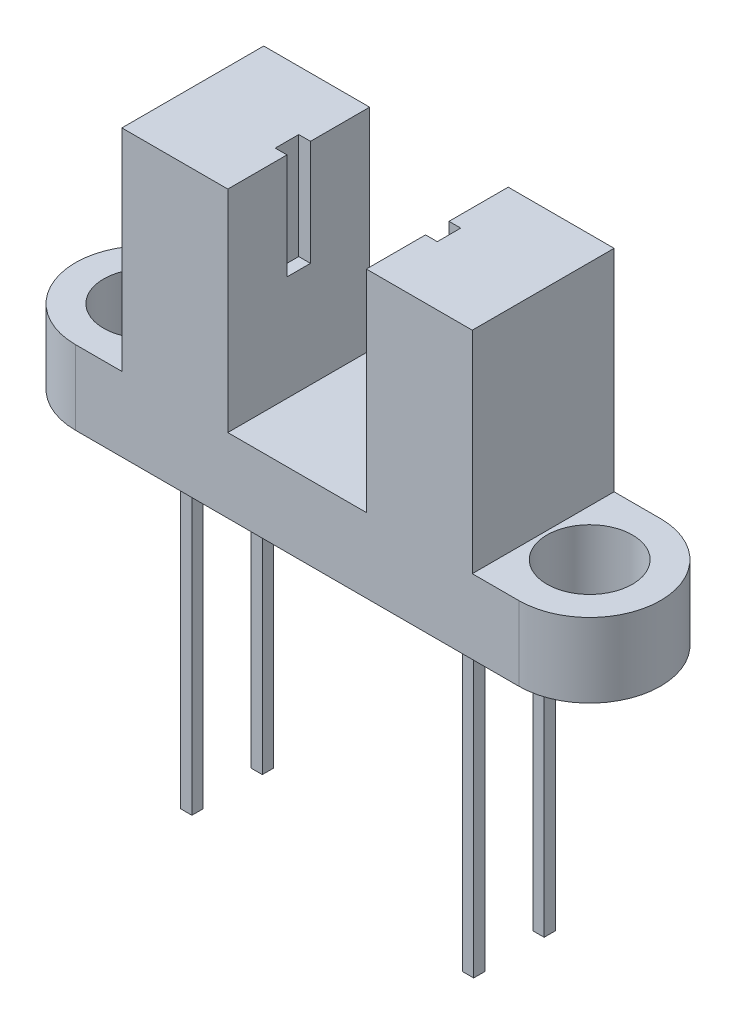
from build123d import *

# Parameters (mm, degrees)
CROQUIS1_R                = 1.82
SALIENTE_EXTRUIR1_DEPTH   = 3.16
CROQUIS2_W                = 4.51
CROQUIS2_H                = 6.04
SALIENTE_EXTRUIR2_DEPTH   = 8.98
CROQUIS3_W                = 0.48
CROQUIS3_H                = 0.48
SALIENTE_EXTRUIR3_DEPTH   = 13
SALIENTE_EXTRUIR3_2_DEPTH = 13
SALIENTE_EXTRUIR3_3_DEPTH = 13
SALIENTE_EXTRUIR3_4_DEPTH = 13
CROQUIS4_W                = 6.9
CROQUIS4_H                = 1
CORTAR_EXTRUIR1_DEPTH     = 4.5


with BuildPart() as part:
    # Croquis1 → Saliente-Extruir1 (new body)
    with BuildSketch(Plane(origin=(0, 0, 0), x_dir=(1, 0, 0), z_dir=(0, 1, 0))):
        with BuildLine():
            Line((-9.44, 3.02), (9.44, 3.02))
            ThreePointArc((9.44, 3.02), (12.46, 0), (9.44, -3.02))
            Line((9.44, -3.02), (-9.44, -3.02))
            ThreePointArc((-9.44, -3.02), (-12.46, 0), (-9.44, 3.02))
        make_face()
        with Locations((-9.44, 0)):
            Circle(CROQUIS1_R, mode=Mode.SUBTRACT)
        with Locations((9.44, 0)):
            Circle(CROQUIS1_R, mode=Mode.SUBTRACT)
    extrude(amount=SALIENTE_EXTRUIR1_DEPTH)

    # Croquis2 → Saliente-Extruir2 (add)
    with BuildSketch(Plane(origin=(0, 3.16, 0), x_dir=(1, 0, 0), z_dir=(0, 1, 0))):
        with Locations((5.205, 0)):
            Rectangle(CROQUIS2_W, CROQUIS2_H)
        with Locations((-5.205, 0)):
            Rectangle(CROQUIS2_W, CROQUIS2_H)
    extrude(amount=SALIENTE_EXTRUIR2_DEPTH)

    # Croquis4 → Cortar-Extruir1 (cut)
    with BuildSketch(Plane(origin=(0, 12.14, 0), x_dir=(1, 0, 0), z_dir=(0, 1, 0))):
        Rectangle(CROQUIS4_W, CROQUIS4_H)
    extrude(amount=-CORTAR_EXTRUIR1_DEPTH, mode=Mode.SUBTRACT)


with BuildPart() as body_2:
    # Croquis3 → Saliente-Extruir3 (new body)
    with BuildSketch(Plane.XZ):
        with Locations((6, 1.5)):
            Rectangle(CROQUIS3_W, CROQUIS3_H)
    extrude(amount=SALIENTE_EXTRUIR3_DEPTH)


with BuildPart() as body_3:
    # Croquis3 → Saliente-Extruir3 2 (new body)
    with BuildSketch(Plane.XZ):
        with Locations((-6, 1.5)):
            Rectangle(CROQUIS3_W, CROQUIS3_H)
    extrude(amount=SALIENTE_EXTRUIR3_2_DEPTH)


with BuildPart() as body_4:
    # Croquis3 → Saliente-Extruir3 3 (new body)
    with BuildSketch(Plane.XZ):
        with Locations((6, -1.5)):
            Rectangle(CROQUIS3_W, CROQUIS3_H)
    extrude(amount=SALIENTE_EXTRUIR3_3_DEPTH)


with BuildPart() as body_5:
    # Croquis3 → Saliente-Extruir3 4 (new body)
    with BuildSketch(Plane.XZ):
        with Locations((-6, -1.5)):
            Rectangle(CROQUIS3_W, CROQUIS3_H)
    extrude(amount=SALIENTE_EXTRUIR3_4_DEPTH)


solid = Compound([part.part, body_2.part, body_3.part, body_4.part, body_5.part])
